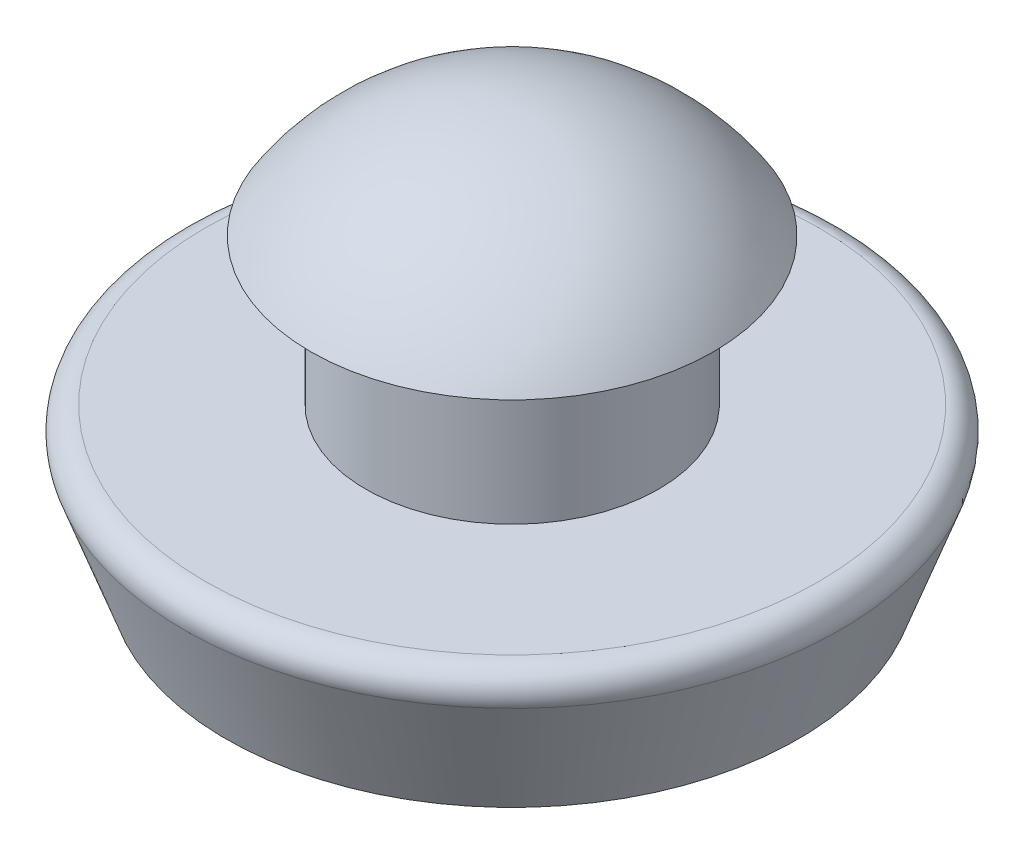
from build123d import *


with BuildPart() as part:
    # Sketch1 → Revolve1 (revolve)
    with BuildSketch(Plane.XY):
        with BuildLine():
            Line((0, 5.55625), (0, -3.175))
            Line((0, -3.175), (-6.20221851, -3.175))
            Line((-6.20221851, -3.175), (-7.11359631, -0.671010072))
            ThreePointArc((-7.11359631, -0.671010072), (-7.053326022, -0.213211782), (-6.64375, 0))
            Line((-6.64375, 0), (-3.175, 0))
            Line((-3.175, 0), (-3.175, 3.175))
            Line((-3.175, 3.175), (-4.365625, 3.175))
            ThreePointArc((-4.365625, 3.175), (-2.486414748, 4.922229122), (0, 5.55625))
        make_face()
    revolve(axis=Axis((0, 5.55625, 0), (0, -1, 0)))


solid = part.part
